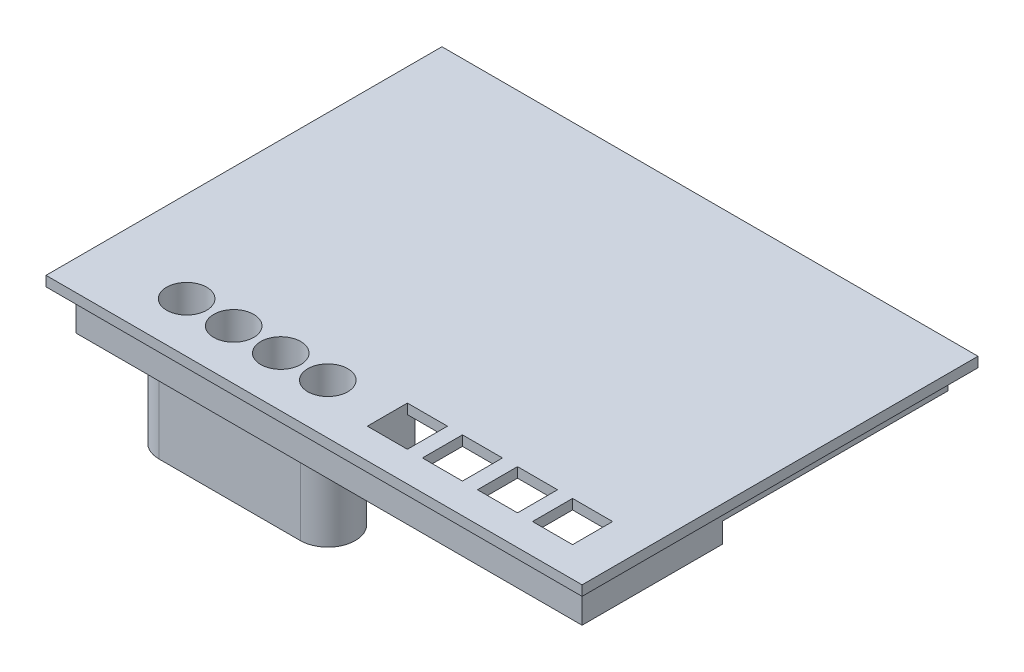
from build123d import *
from build123d.topology import SkipClean

# Parameters (mm, degrees)
SKETCH1_W                 = 78.1
SKETCH1_H                 = 55.9
BOSS_EXTRUDE1_DEPTH       = 3
SKETCH2_R                 = 1.25
CUT_EXTRUDE1_DEPTH        = 68
SKETCH4_W                 = 82.1
SKETCH4_H                 = 59.9
SKETCH4_W_2               = 78.1
SKETCH4_H_2               = 55.9
BOSS_EXTRUDE3_DEPTH       = 3
SKETCH6_R                 = 3
SKETCH6_R_2               = 1.25
BOSS_EXTRUDE4_DEPTH       = 3.5
SKETCH7_W                 = 82.1
SKETCH7_H                 = 16.2
BOSS_EXTRUDE5_DEPTH       = 3
SKETCH8_W                 = 82.1
SKETCH8_H                 = 50.5
BOSS_EXTRUDE6_DEPTH       = 3
SKETCH10_W                = 76.1
SKETCH10_H                = 3
BOSS_EXTRUDE7_DEPTH       = 20
SKETCH12_W                = 79.1
SKETCH12_H                = 50.5
BOSS_EXTRUDE8_DEPTH       = 3
SKETCH17_W                = 105.1
SKETCH17_H                = 50.5
BOSS_EXTRUDE13_DEPTH      = 1
BOSS_EXTRUDE13_DEPTH_BACK = 2
SKETCH18_W                = 11.5
SKETCH18_H                = 7.7
SKETCH18_W_2              = 39.6
SKETCH18_H_2              = 9
CUT_EXTRUDE4_DEPTH        = 9
SKETCH19_W                = 80.1
SKETCH19_H                = 50.5
BOSS_EXTRUDE14_DEPTH      = 3
SKETCH20_R                = 19
SKETCH20_R_2              = 1.5
CUT_EXTRUDE5_DEPTH        = 3
SKETCH22_R                = 2.5
CUT_EXTRUDE6_DEPTH        = 3
SKETCH23_R                = 1.5
BOSS_EXTRUDE16_DEPTH      = 3
SKETCH25_W                = 108.1
SKETCH25_H                = 50.5
CUT_EXTRUDE8_DEPTH        = 0.5
SKETCH26_W                = 79.6
SKETCH26_H                = 50.5
CUT_EXTRUDE9_DEPTH        = 0.5
SKETCH27_W                = 107.6
SKETCH27_H                = 50.5
CUT_EXTRUDE10_DEPTH       = 0.5
SKETCH28_W                = 79.1
SKETCH28_H                = 50.5
CUT_EXTRUDE11_DEPTH       = 0.5
SKETCH30_W                = 101.1
SKETCH30_H                = 73.1
BOSS_EXTRUDE17_DEPTH      = 2
BOSS_EXTRUDE17_DEPTH_BACK = 6
SKETCH31_W                = 39.6
SKETCH31_H                = 15.2
CUT_EXTRUDE12_DEPTH       = 18
SKETCH32_R                = 4
CUT_EXTRUDE13_DEPTH       = 788
SKETCH35_W                = 128.237297138
SKETCH35_H                = 101.417338931
CUT_EXTRUDE16_DEPTH       = 109
SKETCH36_W                = 107.1
SKETCH36_H                = 79.1
SKETCH36_W_2              = 102.1
SKETCH36_H_2              = 74.1
BOSS_EXTRUDE18_DEPTH      = 2
SKETCH37_W                = 107.1
SKETCH37_H                = 79.1
SKETCH37_W_2              = 102.1
SKETCH37_H_2              = 74.1
CUT_EXTRUDE17_DEPTH       = 6
SKETCH38_W                = 102.1
SKETCH38_H                = 74.1
SKETCH38_W_2              = 42.302719986
SKETCH38_H_2              = 18.764227688
BOSS_EXTRUDE19_DEPTH      = 2
SKETCH39_W                = 98.1
SKETCH39_H                = 70.1
CUT_EXTRUDE18_DEPTH       = 6
SKETCH40_R                = 4
BOSS_EXTRUDE21_DEPTH      = 20
SKETCH43_W                = 43.5
SKETCH43_H                = 1.5
CUT_EXTRUDE19_DEPTH       = 20
SKETCH44_W                = 22
SKETCH44_H                = 1.5
CUT_EXTRUDE20_DEPTH       = 20
FILLET1_R                 = 3
SKETCH45_W                = 73.258832398
SKETCH45_H                = 44.668177242
CUT_EXTRUDE21_DEPTH       = 63
CUT_EXTRUDE22_DEPTH       = 380
CUT_EXTRUDE22_DEPTH_BACK  = 374
BOSS_EXTRUDE23_DEPTH      = 2
SKETCH50_R                = 4
BOSS_EXTRUDE24_DEPTH      = 23
FILLET2_R                 = 3
SKETCH51_W                = 22
SKETCH51_H                = 0.5
CUT_EXTRUDE23_DEPTH       = 23
SKETCH52_W                = 22
SKETCH52_H                = 0.5
CUT_EXTRUDE24_DEPTH       = 23
SKETCH53_W                = 8
SKETCH53_H                = 8
CUT_EXTRUDE25_DEPTH       = 23
CUT_EXTRUDE26_DEPTH       = 23
SKETCH56_W                = 3.4
SKETCH56_H                = 1.5
SKETCH56_H_2              = 8
BOSS_EXTRUDE25_DEPTH      = 6
SKETCH58_W                = 4.9
SKETCH58_H                = 11
BOSS_EXTRUDE26_DEPTH      = 6
SKETCH61_R                = 1
CUT_EXTRUDE27_DEPTH       = 6
SKETCH62_W                = 3.4
SKETCH62_H                = 15.6
BOSS_EXTRUDE27_DEPTH      = 6
SKETCH64_W                = 4.9
SKETCH64_H                = 11
SKETCH64_R                = 1
SKETCH64_W_2              = 1.5
SKETCH64_H_2              = 70.1
BOSS_EXTRUDE28_DEPTH      = 2


with BuildPart() as part:
    # Sketch1 → Boss-Extrude1 (new body)
    with BuildSketch(Plane(origin=(0, 0, 0), x_dir=(1, 0, 0), z_dir=(0, 1, 0))):
        Rectangle(SKETCH1_W, SKETCH1_H)
    extrude(amount=BOSS_EXTRUDE1_DEPTH)

    # Sketch2 → Cut-Extrude1 (cut)
    with BuildSketch(Plane(origin=(0, 3, 0), x_dir=(1, 0, 0), z_dir=(0, 1, 0))):
        with Locations(Location((-35.9, 20.9, 0), (0, 0, 270))):
            Circle(SKETCH2_R)
        with Locations(Location((-35.9, -24.8, 0), (0, 0, 270))):
            Circle(SKETCH2_R)
        with Locations(Location((35.9, -24.8, 0), (0, 0, 270))):
            Circle(SKETCH2_R)
        with Locations(Location((35.9, 24.8, 0), (0, 0, 270))):
            Circle(SKETCH2_R)
    extrude(amount=-CUT_EXTRUDE1_DEPTH, mode=Mode.SUBTRACT)

    # Sketch4 → Boss-Extrude3 (add)
    with BuildSketch(Plane(origin=(0, 0, 0), x_dir=(-1, 0, 0), z_dir=(0, -1, 0))):
        Rectangle(SKETCH4_W, SKETCH4_H)
        Rectangle(SKETCH4_W_2, SKETCH4_H_2, mode=Mode.SUBTRACT)
    extrude(amount=-BOSS_EXTRUDE3_DEPTH)

    # Sketch6 → Boss-Extrude4 (add)
    with BuildSketch(Plane(origin=(0, 3, 0), x_dir=(1, 0, 0), z_dir=(0, 1, 0))):
        with Locations(Location((-35.9, 20.9, 0), (0, 0, 90))):
            Circle(SKETCH6_R)
        with Locations(Location((-35.9, 20.9, 0), (0, 0, 270))):
            Circle(SKETCH6_R_2, mode=Mode.SUBTRACT)
        with Locations(Location((35.9, 24.8, 0), (0, 0, 90))):
            Circle(SKETCH6_R)
        with Locations(Location((35.9, 24.8, 0), (0, 0, 270))):
            Circle(SKETCH6_R_2, mode=Mode.SUBTRACT)
        with Locations(Location((35.9, -24.8, 0), (0, 0, 90))):
            Circle(SKETCH6_R)
        with Locations(Location((35.9, -24.8, 0), (0, 0, 270))):
            Circle(SKETCH6_R_2, mode=Mode.SUBTRACT)
        with Locations(Location((-35.9, -24.8, 0), (0, 0, 90))):
            Circle(SKETCH6_R)
        with Locations(Location((-35.9, -24.8, 0), (0, 0, 270))):
            Circle(SKETCH6_R_2, mode=Mode.SUBTRACT)
    extrude(amount=BOSS_EXTRUDE4_DEPTH)

    # Sketch7 → Boss-Extrude5 (add)
    with BuildSketch(Plane(origin=(0, 0, 0), x_dir=(-1, 0, 0), z_dir=(0, -1, 0))):
        with Locations((0, 38.05)):
            Rectangle(SKETCH7_W, SKETCH7_H)
    extrude(amount=-BOSS_EXTRUDE5_DEPTH)

    # Sketch8 → Boss-Extrude6 (add)
    with BuildSketch(Plane(origin=(0, 0, -46.15), x_dir=(-1, 0, 0), z_dir=(0, 0, -1))):
        with Locations((0, 25.25)):
            Rectangle(SKETCH8_W, SKETCH8_H)
    extrude(amount=BOSS_EXTRUDE6_DEPTH)

    # Sketch10 → Boss-Extrude7 (add)
    with BuildSketch(Plane(origin=(41.05, 0, 0), x_dir=(0, 0, -1), z_dir=(1, 0, 0))):
        Polygon((49.15, 50.5), (46.15, 50.5), (46.15, 3), (46.15, 0), (49.15, 0), align=None)
        with Locations((8.1, 1.5)):
            Rectangle(SKETCH10_W, SKETCH10_H)
    extrude(amount=BOSS_EXTRUDE7_DEPTH)

    # Sketch12 → Boss-Extrude8 (add)
    with BuildSketch(Plane.ZY.offset(41.05)):
        with Locations((-9.6, 25.25)):
            Rectangle(SKETCH12_W, SKETCH12_H)
    extrude(amount=BOSS_EXTRUDE8_DEPTH)

    # Sketch17 → Boss-Extrude13 (add, two sides)
    with BuildSketch(Plane.XY.offset(29.95)) as boss_extrude13_sk:
        with Locations((8.5, 25.25)):
            Rectangle(SKETCH17_W, SKETCH17_H)
    extrude(amount=BOSS_EXTRUDE13_DEPTH)
    extrude(boss_extrude13_sk.sketch, amount=-BOSS_EXTRUDE13_DEPTH_BACK)

    # Sketch18 → Cut-Extrude4 (cut)
    with BuildSketch(Plane(origin=(0, 0, 27.95), x_dir=(-1, 0, 0), z_dir=(0, 0, -1))):
        with Locations((-21.6, 9.95)):
            Rectangle(SKETCH18_W, SKETCH18_H)
        with Locations((11.35, 17.6)):
            Rectangle(SKETCH18_W_2, SKETCH18_H_2)
    extrude(amount=-CUT_EXTRUDE4_DEPTH, mode=Mode.SUBTRACT)

    # Sketch19 → Boss-Extrude14 (add)
    with BuildSketch(Plane(origin=(61.05, 0, 0), x_dir=(0, 0, -1), z_dir=(1, 0, 0))):
        with Locations((9.1, 25.25)):
            Rectangle(SKETCH19_W, SKETCH19_H)
    extrude(amount=BOSS_EXTRUDE14_DEPTH)

    # Sketch20 → Cut-Extrude5 (cut)
    with BuildSketch(Plane.ZY.offset(-61.05)):
        with Locations((-24.15, 25)):
            Circle(SKETCH20_R)
        with Locations((-8.4, 40.75)):
            Circle(SKETCH20_R_2)
        with Locations((-39.9, 40.75)):
            Circle(SKETCH20_R_2)
        with Locations((-8.4, 9.25)):
            Circle(SKETCH20_R_2)
        with Locations((-39.9, 9.25)):
            Circle(SKETCH20_R_2)
    extrude(amount=-CUT_EXTRUDE5_DEPTH, mode=Mode.SUBTRACT)

    # Sketch22 → Cut-Extrude6 (cut)
    with BuildSketch(Plane(origin=(-41.05, 0, 0), x_dir=(0, 0, -1), z_dir=(1, 0, 0))):
        with Locations((14.225, 12.6875)):
            Circle(SKETCH22_R)
        with Locations((14.225, 22.0625)):
            Circle(SKETCH22_R)
        with Locations((18.5, 17.375)):
            Circle(SKETCH22_R)
        with Locations((22.775, 22.0625)):
            Circle(SKETCH22_R)
        with Locations((22.775, 12.6875)):
            Circle(SKETCH22_R)
        with Locations((14.225, 31.4375)):
            Circle(SKETCH22_R)
        with Locations((18.5, 26.75)):
            Circle(SKETCH22_R)
        with Locations((22.775, 31.4375)):
            Circle(SKETCH22_R)
        with Locations((18.5, 36.125)):
            Circle(SKETCH22_R)
        with Locations((14.225, 40.8125)):
            Circle(SKETCH22_R)
        with Locations((22.775, 40.8125)):
            Circle(SKETCH22_R)
        with Locations((27.05, 36.125)):
            Circle(SKETCH22_R)
        with Locations((31.325, 40.8125)):
            Circle(SKETCH22_R)
        with Locations((39.875, 40.8125)):
            Circle(SKETCH22_R)
        with Locations((35.6, 36.125)):
            Circle(SKETCH22_R)
        with Locations((39.875, 31.4375)):
            Circle(SKETCH22_R)
        with Locations((31.325, 31.4375)):
            Circle(SKETCH22_R)
        with Locations((27.05, 26.75)):
            Circle(SKETCH22_R)
        with Locations((31.325, 22.0625)):
            Circle(SKETCH22_R)
        with Locations((39.875, 22.0625)):
            Circle(SKETCH22_R)
        with Locations((35.6, 26.75)):
            Circle(SKETCH22_R)
        with Locations((27.05, 17.375)):
            Circle(SKETCH22_R)
        with Locations((31.325, 12.6875)):
            Circle(SKETCH22_R)
        with Locations((39.875, 12.6875)):
            Circle(SKETCH22_R)
        with Locations((35.6, 17.375)):
            Circle(SKETCH22_R)
        with Locations((18.5, 8)):
            Circle(SKETCH22_R)
        with Locations((27.05, 8)):
            Circle(SKETCH22_R)
        with Locations((35.6, 8)):
            Circle(SKETCH22_R)
    extrude(amount=-CUT_EXTRUDE6_DEPTH, mode=Mode.SUBTRACT)

    # Sketch23 → Boss-Extrude16 (add)
    with BuildSketch(Plane(origin=(64.05, 0, 0), x_dir=(0, 0, -1), z_dir=(1, 0, 0))):
        with Locations((8.4, 9.25)):
            Circle(SKETCH23_R)
        with Locations((39.9, 40.75)):
            Circle(SKETCH23_R)
    extrude(amount=-BOSS_EXTRUDE16_DEPTH)

    # Sketch25 → Cut-Extrude8 (cut)
    with BuildSketch(Plane.XY.offset(30.95)):
        with Locations((10, 25.25)):
            Rectangle(SKETCH25_W, SKETCH25_H)
    extrude(amount=-CUT_EXTRUDE8_DEPTH, mode=Mode.SUBTRACT)

    # Sketch26 → Cut-Extrude9 (cut)
    with BuildSketch(Plane(origin=(64.05, 0, 0), x_dir=(0, 0, -1), z_dir=(1, 0, 0))):
        with Locations((9.35, 25.25)):
            Rectangle(SKETCH26_W, SKETCH26_H)
    extrude(amount=-CUT_EXTRUDE9_DEPTH, mode=Mode.SUBTRACT)

    # Sketch27 → Cut-Extrude10 (cut)
    with BuildSketch(Plane(origin=(0, 0, -49.15), x_dir=(-1, 0, 0), z_dir=(0, 0, -1))):
        with Locations((-9.75, 25.25)):
            Rectangle(SKETCH27_W, SKETCH27_H)
    extrude(amount=-CUT_EXTRUDE10_DEPTH, mode=Mode.SUBTRACT)

    # Sketch28 → Cut-Extrude11 (cut)
    with BuildSketch(Plane.ZY.offset(44.05)):
        with Locations((-9.1, 25.25)):
            Rectangle(SKETCH28_W, SKETCH28_H)
    extrude(amount=-CUT_EXTRUDE11_DEPTH, mode=Mode.SUBTRACT)

    # Sketch31 → Cut-Extrude12 (cut)
    with BuildSketch(Plane(origin=(0, 3, 0), x_dir=(1, 0, 0), z_dir=(0, 1, 0))):
        with Locations((-11.35, -20.35)):
            Rectangle(SKETCH31_W, SKETCH31_H)
    extrude(amount=-CUT_EXTRUDE12_DEPTH, mode=Mode.SUBTRACT)


with BuildPart() as body_2:
    # Sketch30 → Boss-Extrude17 (new, two sides)
    with BuildSketch(Plane(origin=(0, 50.5, 0), x_dir=(1, 0, 0), z_dir=(0, 1, 0))) as boss_extrude17_sk:
        with Locations((10, 9.1)):
            Rectangle(SKETCH30_W, SKETCH30_H)
    extrude(amount=BOSS_EXTRUDE17_DEPTH)
    extrude(boss_extrude17_sk.sketch, amount=-BOSS_EXTRUDE17_DEPTH_BACK)


with BuildPart() as cut_extrude13_tool:
    # Sketch32 → Cut-Extrude13 (new body)
    with BuildSketch(Plane.XZ):
        with Locations(Location((2.73, 16.581093047, 0), (0, 0, 270))):
            Circle(SKETCH32_R)
        with Locations(Location((-6.607184449, 16.581093047, 0), (0, 0, 270))):
            Circle(SKETCH32_R)
        with Locations(Location((-16.03, 16.55, 0), (0, 0, 270))):
            Circle(SKETCH32_R)
        with Locations(Location((-25.43, 16.55, 0), (0, 0, 270))):
            Circle(SKETCH32_R)
    extrude(amount=-CUT_EXTRUDE13_DEPTH)


with BuildPart() as part_1:
    add(part.part)

    # Cut-Extrude13: cut by cut_extrude13_tool
    add(cut_extrude13_tool.part, mode=Mode.SUBTRACT)

    # Sketch35 → Cut-Extrude16 (cut)
    with BuildSketch(Plane.XY.offset(30.45)):
        with Locations((20.568648569, -6.208669466)):
            Rectangle(SKETCH35_W, SKETCH35_H)
    extrude(amount=-CUT_EXTRUDE16_DEPTH, mode=Mode.SUBTRACT)

    # Sketch36 → Boss-Extrude18 (add)
    with BuildSketch(Plane(origin=(0, 50.5, 0), x_dir=(1, 0, 0), z_dir=(0, 1, 0))):
        with Locations((10, 9.1)):
            Rectangle(SKETCH36_W, SKETCH36_H)
        with Locations((10, 9.1)):
            Rectangle(SKETCH36_W_2, SKETCH36_H_2, mode=Mode.SUBTRACT)
    extrude(amount=BOSS_EXTRUDE18_DEPTH)

    # Sketch37 → Cut-Extrude17 (cut)
    with BuildSketch(Plane(origin=(0, 44.5, 0), x_dir=(-1, 0, 0), z_dir=(0, -1, 0))):
        with Locations((-10, 9.1)):
            Rectangle(SKETCH37_W, SKETCH37_H)
        with Locations((-10, 9.1)):
            Rectangle(SKETCH37_W_2, SKETCH37_H_2, mode=Mode.SUBTRACT)
    extrude(amount=-CUT_EXTRUDE17_DEPTH, mode=Mode.SUBTRACT)



with BuildPart() as body_2_1:
    add(body_2.part)

    # Cut-Extrude13: cut by cut_extrude13_tool
    add(cut_extrude13_tool.part, mode=Mode.SUBTRACT)


with BuildPart() as part_2:
    add(part_1.part)

    add(body_2_1.part)  # Boss-Extrude19 merges body 2
    # Sketch38 → Boss-Extrude19 (add)
    with BuildSketch(Plane(origin=(0, 52.5, 0), x_dir=(1, 0, 0), z_dir=(0, 1, 0))):
        with Locations((10, 9.1)):
            Rectangle(SKETCH38_W, SKETCH38_H)
        with Locations((-11.151359993, -15.547609528)):
            Rectangle(SKETCH38_W_2, SKETCH38_H_2, mode=Mode.SUBTRACT)
    extrude(amount=-BOSS_EXTRUDE19_DEPTH)

    # Sketch39 → Cut-Extrude18 (cut)
    with BuildSketch(Plane(origin=(0, 44.5, 0), x_dir=(-1, 0, 0), z_dir=(0, -1, 0))):
        with Locations((-10, 9.1)):
            Rectangle(SKETCH39_W, SKETCH39_H)
    extrude(amount=-CUT_EXTRUDE18_DEPTH, mode=Mode.SUBTRACT)

    # Sketch40 → Boss-Extrude21 (add)
    with BuildSketch(Plane(origin=(0, 50.5, 0), x_dir=(-1, 0, 0), z_dir=(0, -1, 0))):
        with BuildLine():
            Line((25.43, -11.181722504), (-2.73, -11.243908599))
            ThreePointArc((-2.73, -11.243908599), (-8.067184449, -16.581093047), (-2.73, -21.918277496))
            Line((-2.73, -21.918277496), (25.43, -21.918277496))
            ThreePointArc((25.43, -21.918277496), (30.798277496, -16.55), (25.43, -11.181722504))
        make_face()
        with Locations(Location((6.607184449, -16.581093047, 0), (0, 0, 90))):
            Circle(SKETCH40_R, mode=Mode.SUBTRACT)
        with Locations(Location((16.03, -16.55, 0), (0, 0, 90))):
            Circle(SKETCH40_R, mode=Mode.SUBTRACT)
        with Locations(Location((25.43, -16.55, 0), (0, 0, 90))):
            Circle(SKETCH40_R, mode=Mode.SUBTRACT)
        with Locations(Location((-2.73, -16.581093047, 0), (0, 0, 90))):
            Circle(SKETCH40_R, mode=Mode.SUBTRACT)
    extrude(amount=BOSS_EXTRUDE21_DEPTH)

    # Sketch43 → Cut-Extrude19 (cut)
    with BuildSketch(Plane.ZY.offset(-59.05)):
        with Locations((-22.4, 45.25)):
            Rectangle(SKETCH43_W, SKETCH43_H)
    extrude(amount=-CUT_EXTRUDE19_DEPTH, mode=Mode.SUBTRACT)

    # Sketch44 → Cut-Extrude20 (cut)
    with BuildSketch(Plane.XY.offset(-44.15)):
        with Locations((49.55, 45.25)):
            Rectangle(SKETCH44_W, SKETCH44_H)
    extrude(amount=-CUT_EXTRUDE20_DEPTH, mode=Mode.SUBTRACT)

    # Fillet1
    fillet1_edges = [part_2.edges().sort_by_distance(p)[0] for p in [
        (-11.35, 50.5, 21.918277496),
        (-30.798277496, 50.5, 16.55),
        (-11.35, 50.5, 11.212815551),
        (8.067184449, 50.5, 16.581093047),
    ]]
    fillet(fillet1_edges, radius=FILLET1_R)

    # Sketch45 → Cut-Extrude21 (cut)
    with BuildSketch(Plane(origin=(0, 50.5, 0), x_dir=(-1, 0, 0), z_dir=(0, -1, 0))):
        with Locations((2.420583801, -3.615911379)):
            Rectangle(SKETCH45_W, SKETCH45_H)
    extrude(amount=CUT_EXTRUDE21_DEPTH, mode=Mode.SUBTRACT)

    # Sketch3 → Cut-Extrude22 (cut, two sides)
    with BuildSketch(Plane(origin=(0, 3, 0), x_dir=(1, 0, 0), z_dir=(0, 1, 0))) as cut_extrude22_sk:
        with BuildLine():
            ThreePointArc((-21.45, -20.45), (-25.45, -16.45), (-29.45, -20.45))
            Line((-29.45, -20.45), (-25.45, -20.45))
            Line((-25.45, -20.45), (-21.45, -20.45))
        make_face()
        with BuildLine():
            ThreePointArc((-29.45, -20.45), (-28.278427125, -23.278427125), (-25.45, -24.45))
            Line((-25.45, -24.45), (-25.45, -20.45))
            Line((-25.45, -20.45), (-29.45, -20.45))
        make_face()
        with BuildLine():
            Line((-25.45, -20.45), (-25.45, -24.45))
            ThreePointArc((-25.45, -24.45), (-22.621572875, -23.278427125), (-21.45, -20.45))
            Line((-21.45, -20.45), (-25.45, -20.45))
        make_face()
        with BuildLine():
            ThreePointArc((-20.05, -20.45), (-18.878427125, -23.278427125), (-16.05, -24.45))
            Line((-16.05, -24.45), (-16.05, -20.45))
            Line((-16.05, -20.45), (-20.05, -20.45))
        make_face()
        with BuildLine():
            Line((-16.05, -20.45), (-16.05, -24.45))
            ThreePointArc((-16.05, -24.45), (-13.221572875, -23.278427125), (-12.05, -20.45))
            ThreePointArc((-12.05, -20.45), (-16.05, -16.45), (-20.05, -20.45))
            Line((-20.05, -20.45), (-16.05, -20.45))
        make_face()
        with BuildLine():
            ThreePointArc((-2.65, -20.45), (-9.478427125, -17.621572875), (-6.65, -24.45))
            Line((-6.65, -24.45), (-6.65, -20.45))
            Line((-6.65, -20.45), (-2.65, -20.45))
        make_face()
        with BuildLine():
            Line((-6.65, -20.45), (-6.65, -24.45))
            ThreePointArc((-6.65, -24.45), (-3.821572875, -23.278427125), (-2.65, -20.45))
            Line((-2.65, -20.45), (-6.65, -20.45))
        make_face()
        with BuildLine():
            ThreePointArc((-1.25, -20.45), (-0.078427125, -23.278427125), (2.75, -24.45))
            Line((2.75, -24.45), (2.75, -20.45))
            Line((2.75, -20.45), (-1.25, -20.45))
        make_face()
        with BuildLine():
            Line((2.75, -20.45), (2.75, -24.45))
            ThreePointArc((2.75, -24.45), (5.578427125, -23.278427125), (6.75, -20.45))
            Line((6.75, -20.45), (2.75, -20.45))
        make_face()
        with BuildLine():
            Line((2.75, -20.45), (6.75, -20.45))
            ThreePointArc((6.75, -20.45), (2.75, -16.45), (-1.25, -20.45))
            Line((-1.25, -20.45), (2.75, -20.45))
        make_face()
    extrude(amount=CUT_EXTRUDE22_DEPTH, mode=Mode.SUBTRACT)
    extrude(cut_extrude22_sk.sketch, amount=-CUT_EXTRUDE22_DEPTH_BACK, mode=Mode.SUBTRACT)

    # Sketch49 → Boss-Extrude23 (add)
    with BuildSketch(Plane(origin=(0, 50.5, 0), x_dir=(-1, 0, 0), z_dir=(0, -1, 0))):
        with BuildLine():
            ThreePointArc((-6.241065865, -18.497448048), (-2.729322601, -16.450053445), (0.761065865, -18.533644999))
            ThreePointArc((0.761065865, -18.533644999), (1.140675875, -17.589987625), (1.27, -16.581093047))
            ThreePointArc((1.27, -16.581093047), (-3.718872221, -12.70525356), (-6.241065865, -18.497448048))
        make_face()
        with BuildLine():
            ThreePointArc((3.127745115, -18.554288913), (6.605736408, -16.450244916), (10.129439334, -18.476804135))
            ThreePointArc((10.129439334, -18.476804135), (10.485909725, -17.558584853), (10.607184449, -16.581093047))
            ThreePointArc((10.607184449, -16.581093047), (5.586830916, -12.713422086), (3.127745115, -18.554288913))
        make_face()
        with BuildLine():
            ThreePointArc((12.547568292, -18.517909906), (16.029487449, -16.450052596), (19.532431708, -18.482090094))
            ThreePointArc((19.532431708, -18.482090094), (19.90361116, -17.547565328), (20.03, -16.55))
            ThreePointArc((20.03, -16.55), (15.012583377, -12.681555427), (12.547568292, -18.517909906))
        make_face()
        with BuildLine():
            ThreePointArc((21.947568292, -18.517909906), (25.429487449, -16.450052596), (28.932431708, -18.482090094))
            ThreePointArc((28.932431708, -18.482090094), (29.30361116, -17.547565328), (29.43, -16.55))
            ThreePointArc((29.43, -16.55), (24.412583377, -12.681555427), (21.947568292, -18.517909906))
        make_face()
    extrude(amount=-BOSS_EXTRUDE23_DEPTH)

    # Sketch50 → Boss-Extrude24 (add)
    with SkipClean():  # the faces are left unmerged after this step: merging them gives an invalid solid
        with BuildSketch(Plane(origin=(0, 50.5, 0), x_dir=(-1, 0, 0), z_dir=(0, -1, 0))):
            with BuildLine():
                Line((-2.75, -25.95), (25.45, -25.95))
                ThreePointArc((25.45, -25.95), (30.95, -20.45), (25.45, -14.95))
                Line((25.45, -14.95), (-2.75, -14.95))
                ThreePointArc((-2.75, -14.95), (-8.25, -20.45), (-2.75, -25.95))
            make_face()
            with Locations(Location((16.05, -20.45, 0), (0, 0, 90))):
                Circle(SKETCH50_R, mode=Mode.SUBTRACT)
            with Locations(Location((6.65, -20.45, 0), (0, 0, 90))):
                Circle(SKETCH50_R, mode=Mode.SUBTRACT)
            with Locations(Location((25.45, -20.45, 0), (0, 0, 90))):
                Circle(SKETCH50_R, mode=Mode.SUBTRACT)
            with Locations(Location((-2.75, -20.45, 0), (0, 0, 90))):
                Circle(SKETCH50_R, mode=Mode.SUBTRACT)
        extrude(amount=BOSS_EXTRUDE24_DEPTH)

    # Fillet2
    fillet2_edges = [part_2.edges().sort_by_distance(p)[0] for p in [
        (-11.35, 50.5, 14.95),
        (8.25, 50.5, 20.45),
        (-30.95, 50.5, 20.45),
    ]]
    fillet(fillet2_edges, radius=FILLET2_R)

    # Sketch51 → Cut-Extrude23 (cut)
    with SkipClean():  # the faces are left unmerged after this step: merging them gives an invalid solid
        with BuildSketch(Plane(origin=(0, 0, -45.65), x_dir=(-1, 0, 0), z_dir=(0, 0, -1))):
            with Locations((-49.55, 46.25)):
                Rectangle(SKETCH51_W, SKETCH51_H)
        extrude(amount=-CUT_EXTRUDE23_DEPTH, mode=Mode.SUBTRACT)

    # Sketch52 → Cut-Extrude24 (cut)
    with SkipClean():  # the faces are left unmerged after this step: merging them gives an invalid solid
        with BuildSketch(Plane(origin=(60.55, 0, 0), x_dir=(0, 0, -1), z_dir=(1, 0, 0))):
            with Locations((11.65, 46.25)):
                Rectangle(SKETCH52_W, SKETCH52_H)
        extrude(amount=-CUT_EXTRUDE24_DEPTH, mode=Mode.SUBTRACT)

    # Sketch53 → Cut-Extrude25 (cut)
    with SkipClean():  # the faces are left unmerged after this step: merging them gives an invalid solid
        with BuildSketch(Plane(origin=(0, 52.5, 0), x_dir=(1, 0, 0), z_dir=(0, 1, 0))):
            with Locations((51.65, -20.45)):
                Rectangle(SKETCH53_W, SKETCH53_H)
            with Locations((40.65, -20.45)):
                Rectangle(SKETCH53_W, SKETCH53_H)
            with Locations((29.65, -20.45)):
                Rectangle(SKETCH53_W, SKETCH53_H)
            with Locations((18.65, -20.45)):
                Rectangle(SKETCH53_W, SKETCH53_H)
        extrude(amount=-CUT_EXTRUDE25_DEPTH, mode=Mode.SUBTRACT)

    # Sketch54 → Cut-Extrude26 (cut)
    with SkipClean():  # the faces are left unmerged after this step: merging them gives an invalid solid
        with BuildSketch(Plane(origin=(0, 27.5, 0), x_dir=(-1, 0, 0), z_dir=(0, -1, 0))):
            Polygon((-14.201290386, -14.95), (-2.75, -14.95), (25.45, -14.95), (35.501290386, -14.95), (35.501290386, -4.067232411), (-14.201290386, -4.067232411), align=None)
            with BuildLine():
                Line((35.501290386, -14.95), (25.45, -14.95))
                ThreePointArc((25.45, -14.95), (29.339087297, -16.560912703), (30.95, -20.45))
                ThreePointArc((30.95, -20.45), (29.339087297, -24.339087297), (25.45, -25.95))
                Line((25.45, -25.95), (35.501290386, -25.95))
                Line((35.501290386, -25.95), (35.501290386, -14.95))
            make_face()
            with BuildLine():
                ThreePointArc((-2.75, -25.95), (-8.25, -20.45), (-2.75, -14.95))
                Line((-2.75, -14.95), (-14.201290386, -14.95))
                Line((-14.201290386, -14.95), (-14.201290386, -25.95))
                Line((-14.201290386, -25.95), (-2.75, -25.95))
            make_face()
        extrude(amount=-CUT_EXTRUDE26_DEPTH, mode=Mode.SUBTRACT)

    # Sketch56 → Boss-Extrude25 (add)
    with SkipClean():  # the faces are left unmerged after this step: merging them gives an invalid solid
        with BuildSketch(Plane.XZ.offset(-50.5)):
            with Locations((57.35, 25.2)):
                Rectangle(SKETCH56_W, SKETCH56_H)
            with Locations((57.35, 20.45)):
                Rectangle(SKETCH56_W, SKETCH56_H_2)
            with Locations((57.35, 15.7)):
                Rectangle(SKETCH56_W, SKETCH56_H)
        extrude(amount=BOSS_EXTRUDE25_DEPTH)

    # Sketch58 → Boss-Extrude26 (add)
    with SkipClean():  # the faces are left unmerged after this step: merging them gives an invalid solid
        with BuildSketch(Plane.XZ.offset(-50.5)):
            with Locations((12.2, 20.45)):
                Rectangle(SKETCH58_W, SKETCH58_H)
        extrude(amount=BOSS_EXTRUDE26_DEPTH)

    # Sketch61 → Cut-Extrude27 (cut)
    with SkipClean():  # the faces are left unmerged after this step: merging them gives an invalid solid
        with BuildSketch(Plane(origin=(0, 44.5, 0), x_dir=(-1, 0, 0), z_dir=(0, -1, 0))):
            with Locations(Location((-58.15, -20.45, 0), (0, 0, 90))):
                Circle(SKETCH61_R)
            with Locations(Location((-12.15, -20.45, 0), (0, 0, 90))):
                Circle(SKETCH61_R)
        extrude(amount=-CUT_EXTRUDE27_DEPTH, mode=Mode.SUBTRACT)

    # Sketch62 → Boss-Extrude27 (add)
    with SkipClean():  # the faces are left unmerged after this step: merging them gives an invalid solid
        with BuildSketch(Plane(origin=(0, 44.5, 0), x_dir=(-1, 0, 0), z_dir=(0, -1, 0))):
            with Locations((-57.35, -7.15)):
                Rectangle(SKETCH62_W, SKETCH62_H)
        extrude(amount=-BOSS_EXTRUDE27_DEPTH)

    # Sketch64 → Boss-Extrude28 (add)
    with BuildSketch(Plane.XZ.offset(-44.5)):
        with Locations((12.2, 20.45)):
            Rectangle(SKETCH64_W, SKETCH64_H)
        with Locations(Location((12.15, 20.45, 0), (0, 0, 270))):
            Circle(SKETCH64_R, mode=Mode.SUBTRACT)
        Polygon((55.65, 27.45), (55.65, 25.95), (55.65, -0.65), (60.55, -0.65), (60.55, 27.45), align=None)
        with Locations(Location((58.15, 20.45, 0), (0, 0, 270))):
            Circle(SKETCH64_R, mode=Mode.SUBTRACT)
        Polygon((2.75, 25.95), (9.75, 25.95), (14.65, 25.95), (55.65, 25.95), (55.65, 27.45), (-40.55, 27.45), (-40.55, 25.95), (-39.05, 25.95), (-25.45, 25.95), align=None)
        with Locations((-39.8, -9.1)):
            Rectangle(SKETCH64_W_2, SKETCH64_H_2)
        Polygon((38.55, -44.15), (-39.05, -44.15), (-40.55, -44.15), (-40.55, -45.65), (38.55, -45.65), align=None)
    extrude(amount=BOSS_EXTRUDE28_DEPTH)


solid = part_2.part
